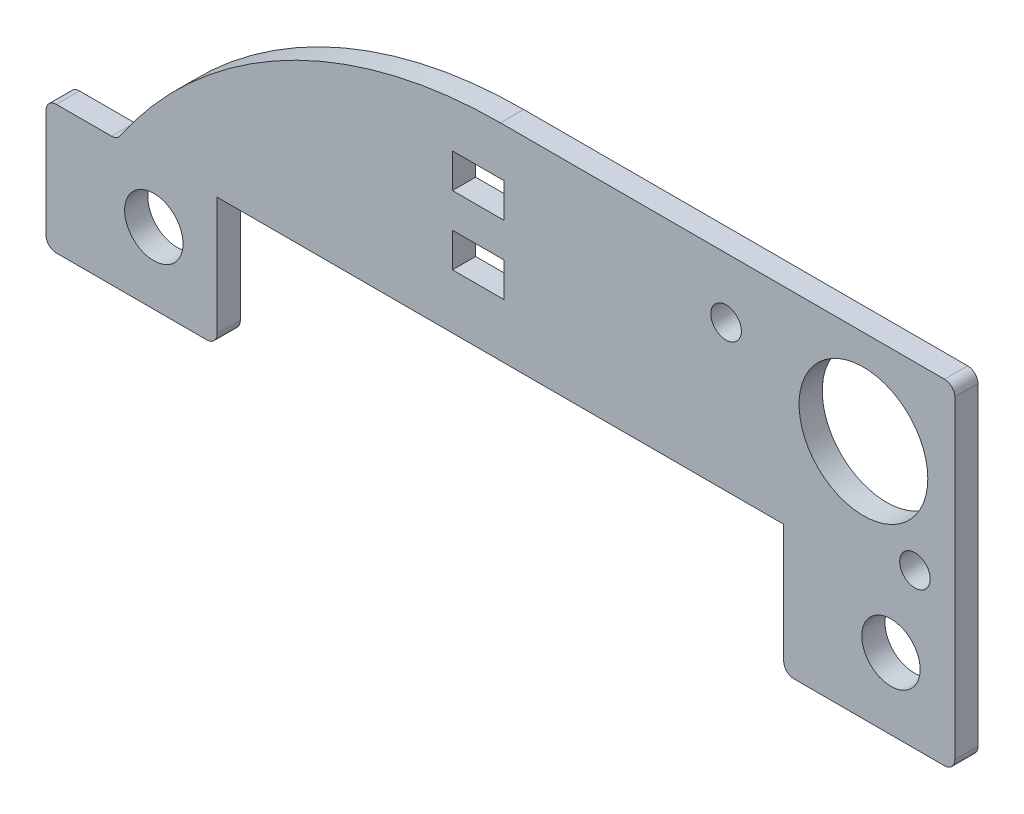
from build123d import *

# Parameters (mm, degrees)
SKETCH1_R           = 4.7625
SKETCH1_R_2         = 2.159
SKETCH1_R_3         = 1.1303
BOSS_EXTRUDE1_DEPTH = 1.7145
SKETCH2_W           = 3.81
SKETCH2_H           = 2.54
CUT_EXTRUDE1_DEPTH  = 1.7145
SKETCH3_W           = 41.91
SKETCH3_H           = 9.525
CUT_EXTRUDE2_DEPTH  = 1.7145
FILLET1_R           = 0.762


with BuildPart() as part:
    # Sketch1 → Boss-Extrude1 (new body)
    with BuildSketch(Plane.XY):
        with BuildLine():
            Line((-33.613, 9.245), (33.613, 9.245))
            Line((33.613, 9.245), (33.613, 34.01))
            Line((33.613, 34.01), (0, 34.01))
            ThreePointArc((0, 34.01), (-16.098329106, 29.958703243), (-28.361368091, 18.77))
            Line((-28.361368091, 18.77), (-33.613, 18.77))
            Line((-33.613, 18.77), (-33.613, 9.245))
        make_face()
        with Locations((26.852588835, 27.025)):
            Circle(SKETCH1_R, mode=Mode.SUBTRACT)
        with Locations((-25.6374, 14.5155)):
            Circle(SKETCH1_R_2, mode=Mode.SUBTRACT)
        with Locations((28.8886, 14.5155)):
            Circle(SKETCH1_R_2, mode=Mode.SUBTRACT)
        with Locations((30.662588835, 20.675)):
            Circle(SKETCH1_R_3, mode=Mode.SUBTRACT)
        with Locations((16.692588835, 29.565)):
            Circle(SKETCH1_R_3, mode=Mode.SUBTRACT)
    extrude(amount=BOSS_EXTRUDE1_DEPTH)

    # Sketch2 → Cut-Extrude1 (cut)
    with BuildSketch(Plane.XY.offset(1.7145)):
        with Locations((-1.644140797, 29.166672544)):
            Rectangle(SKETCH2_W, SKETCH2_H)
        with Locations((-1.644140797, 24.086672544)):
            Rectangle(SKETCH2_W, SKETCH2_H)
    extrude(amount=-CUT_EXTRUDE1_DEPTH, mode=Mode.SUBTRACT)

    # Sketch3 → Cut-Extrude2 (cut)
    with BuildSketch(Plane.XY.offset(1.7145)):
        with Locations((0, 14.0075)):
            Rectangle(SKETCH3_W, SKETCH3_H)
    extrude(amount=-CUT_EXTRUDE2_DEPTH, mode=Mode.SUBTRACT)

    # Fillet1
    fillet1_edges = [part.edges().sort_by_distance(p)[0] for p in [
        (-28.361368091, 18.77, 0.85725),
        (33.613, 34.01, 0.85725),
        (33.613, 9.245, 0.85725),
        (-33.613, 9.245, 0.85725),
        (-33.613, 18.77, 0.85725),
        (-20.955, 9.245, 0.85725),
        (20.955, 9.245, 0.85725),
    ]]
    fillet(fillet1_edges, radius=FILLET1_R)


solid = part.part
